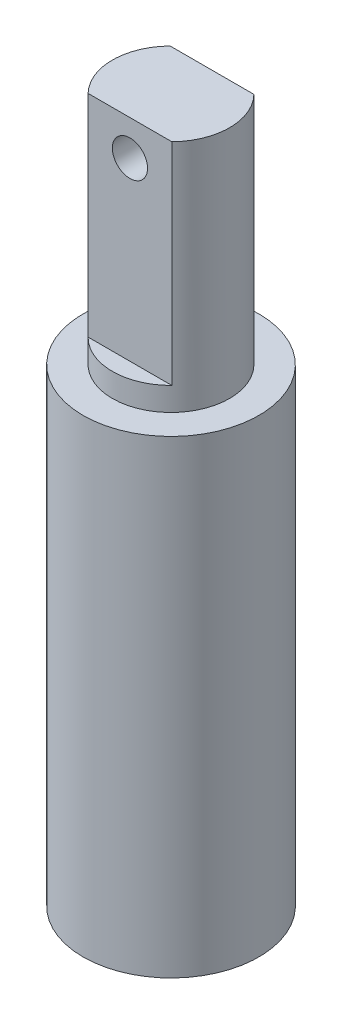
from build123d import *

# Parameters (mm, degrees)
SZKIC1_R                    = 7.5
SZKIC1_R_2                  = 5
DODANIE_WYCI_GNI_CIE1_DEPTH = 40
DODANIE_WYCI_GNI_CIE2_START = 10
SZKIC1_2_R                  = 5
DODANIE_WYCI_GNI_CIE2_DEPTH = 50
SZKIC2_OUTSIDE_W            = 29.728
SZKIC2_OUTSIDE_H            = 29.728
SZKIC2_OUTSIDE_W_2          = 10
SZKIC2_OUTSIDE_H_2          = 7
WYTNIJ_WYCI_GNI_CIE1_DEPTH  = 18
SZKIC3_R                    = 1.5
WYTNIJ_WYCI_GNI_CIE2_DEPTH  = 10


with BuildPart() as part:
    # Szkic1 → Dodanie-wyci_gni_cie1 (new body)
    with BuildSketch(Plane(origin=(0, 0, 0), x_dir=(1, 0, 0), z_dir=(0, 1, 0))):
        Circle(SZKIC1_R)
        Circle(SZKIC1_R_2, mode=Mode.SUBTRACT)
    extrude(amount=DODANIE_WYCI_GNI_CIE1_DEPTH)

    # Szkic1_2 → Dodanie-wyci_gni_cie2 (add)
    with BuildSketch(Plane(origin=(0, 0, 0), x_dir=(1, 0, 0), z_dir=(0, 1, 0)).offset(DODANIE_WYCI_GNI_CIE2_START)):
        Circle(SZKIC1_2_R)
    extrude(amount=DODANIE_WYCI_GNI_CIE2_DEPTH)

    # Szkic2 outside → Wytnij-wyci_gni_cie1 (cut)
    with BuildSketch(Plane(origin=(0, 60, 0), x_dir=(1, 0, 0), z_dir=(0, 1, 0))):
        Rectangle(SZKIC2_OUTSIDE_W, SZKIC2_OUTSIDE_H)
        Rectangle(SZKIC2_OUTSIDE_W_2, SZKIC2_OUTSIDE_H_2, mode=Mode.SUBTRACT)
    extrude(amount=-WYTNIJ_WYCI_GNI_CIE1_DEPTH, mode=Mode.SUBTRACT)

    # Szkic3 → Wytnij-wyci_gni_cie2 (cut)
    with BuildSketch(Plane.XY.offset(3.5)):
        with Locations((0, 57)):
            Circle(SZKIC3_R)
    extrude(amount=-WYTNIJ_WYCI_GNI_CIE2_DEPTH, mode=Mode.SUBTRACT)


solid = part.part
